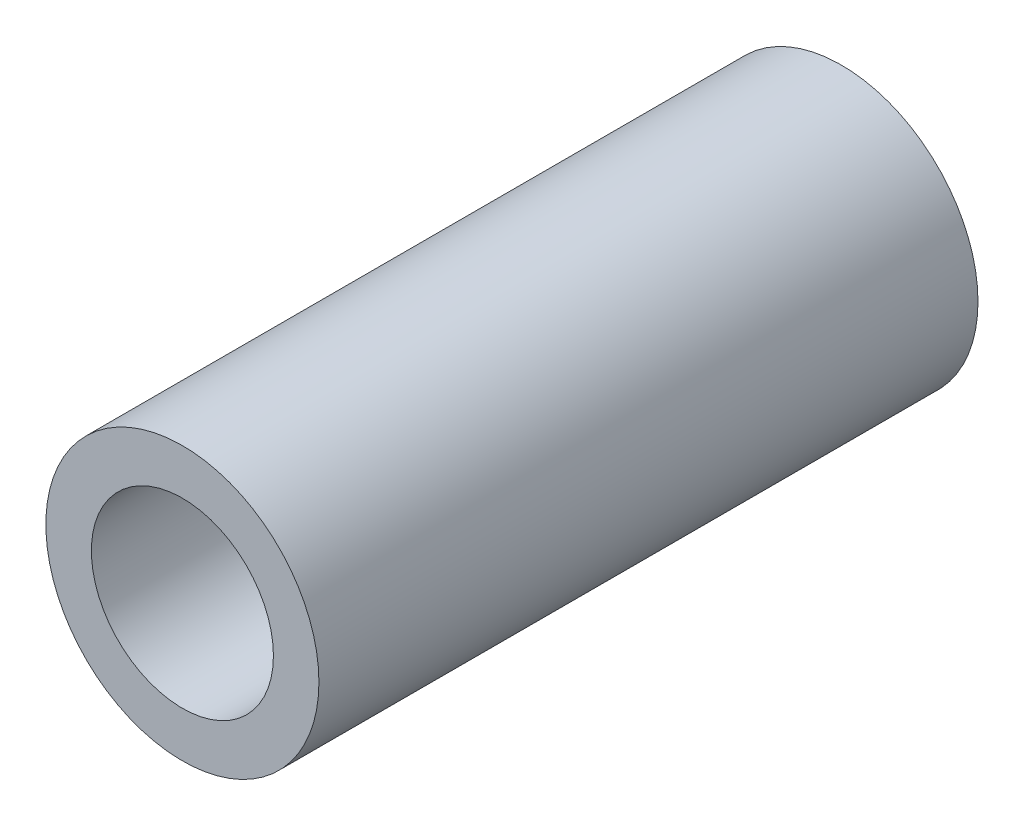
from build123d import *

# Parameters (mm, degrees)
SKETCH1_R           = 9.525
SKETCH1_R_2         = 6.35
BOSS_EXTRUDE1_DEPTH = 45.974


with BuildPart() as part:
    # Sketch1 → Boss-Extrude1 (new body)
    with BuildSketch(Plane.XY):
        Circle(SKETCH1_R)
        Circle(SKETCH1_R_2, mode=Mode.SUBTRACT)
    extrude(amount=BOSS_EXTRUDE1_DEPTH)


solid = part.part
